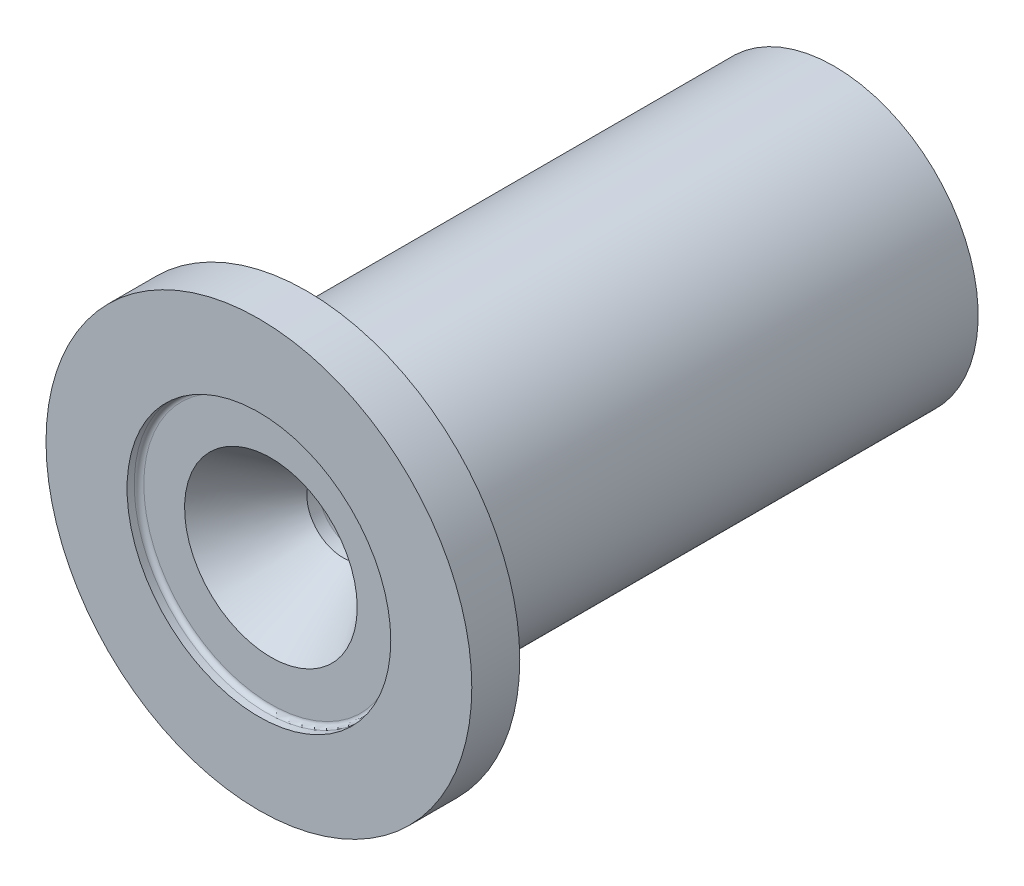
from build123d import *

# Parameters (mm, degrees)
FILLET1_R          = 6.35
SKETCH2_R          = 34.925
CUT_EXTRUDE1_DEPTH = 3.175
FILLET2_R          = 1.27


with BuildPart() as part:
    # Sketch1 → Revolve1 (revolve)
    with BuildSketch(Plane(origin=(0, 0, 0), x_dir=(0, 0, -1), z_dir=(1, 0, 0))):
        Polygon((-76.2, 25.087112537), (-53.975, 9.525), (-50.8, 9.525), (76.2, 31.91852655), (76.2, 38.1), (-63.5, 38.1), (-63.5, 56.388), (-76.2, 56.388), align=None)
    revolve(axis=Axis((0, 0, 76.2), (0, 0, -1)))

    # Fillet1
    fillet1_edges = [part.edges().sort_by_distance(p)[0] for p in [
        (0, -38.1, 63.5),
    ]]
    fillet(fillet1_edges, radius=FILLET1_R)

    # Sketch2 → Cut-Extrude1 (cut)
    with BuildSketch(Plane.XY.offset(76.2)):
        Circle(SKETCH2_R)
    extrude(amount=-CUT_EXTRUDE1_DEPTH, mode=Mode.SUBTRACT)

    # Fillet2
    fillet2_edges = [part.edges().sort_by_distance(p)[0] for p in [
        (-34.925, 0, 73.025),
    ]]
    fillet(fillet2_edges, radius=FILLET2_R)


solid = part.part
